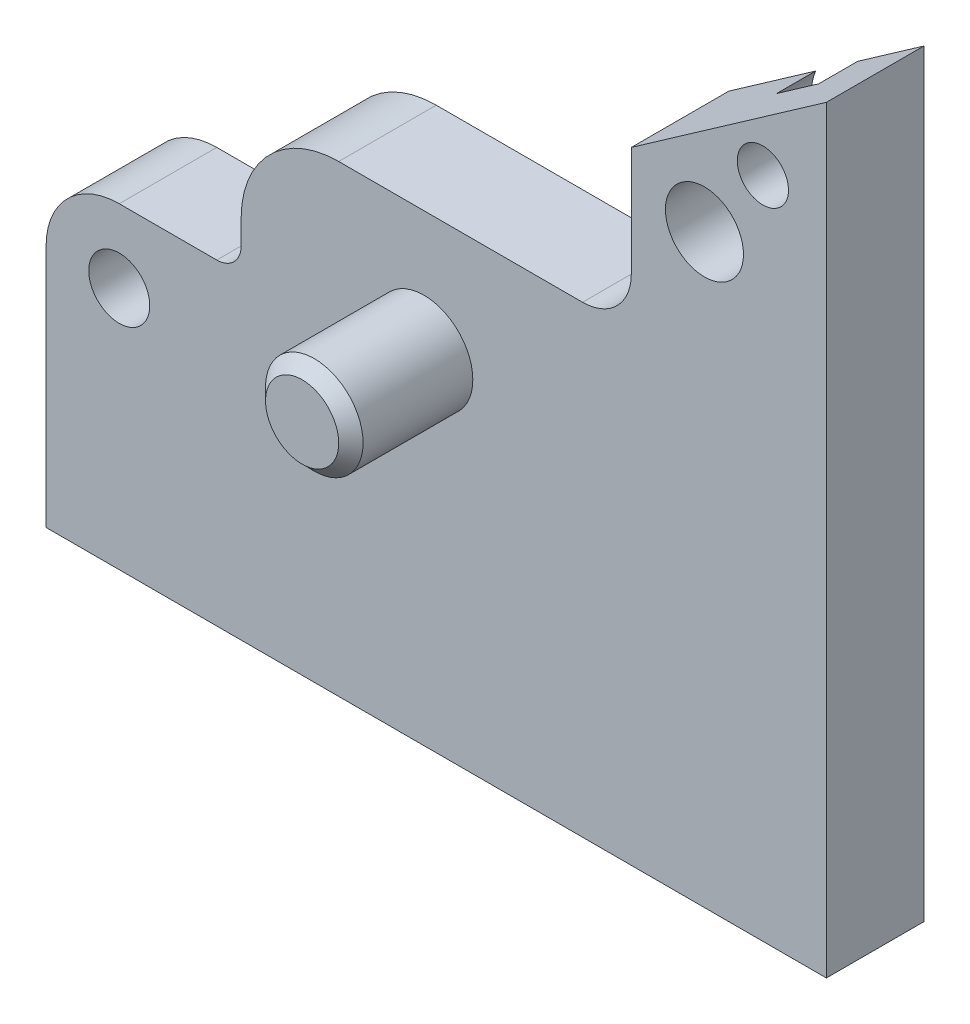
from build123d import *

# Parameters (mm, degrees)
SKETCH1_W                       = 32
SKETCH1_H                       = 25.5
BOSS_EXTRUDE1_DEPTH             = 4
SKETCH2_W                       = 8
SKETCH2_H                       = 12.5
CUT_EXTRUDE1_DEPTH              = 5
SKETCH3_W                       = 16
SKETCH3_H                       = 6.5
CUT_EXTRUDE2_DEPTH              = 5
DRAFT1_ANGLE                    = 35.000000002
SKETCH4_W                       = 2
SKETCH4_H                       = 5
SKETCH5_W                       = 2
SKETCH5_H                       = 5
F_2_5_2_5_DIAMETER_HOLE1_D      = 2.5
F_2_5_2_5_DIAMETER_HOLE1_DEPTH  = 9
F_3_2_3_2_DIAMETER_HOLE1_D      = 3.2
F_3_2_3_2_DIAMETER_HOLE1_DEPTH  = 9
M4X0_7_TAPPED_HOLE1_D           = 2.1
M4X0_7_TAPPED_HOLE1_DEPTH       = 9
M4X0_7_TAPPED_HOLE1_CBORE_D     = 4
M4X0_7_TAPPED_HOLE1_CBORE_DEPTH = 1.6
F_2_5_2_5_DIAMETER_HOLE2_D      = 2.5
F_2_5_2_5_DIAMETER_HOLE2_DEPTH  = 7.5
F_2_5_2_5_DIAMETER_HOLE2_TIP    = 0.751075774
CHAMFER1_SIZE                   = 0.5
FILLET1_R                       = 1
FILLET2_R                       = 2
FILLET3_R                       = 3
FILLET4_R                       = 4


with BuildPart() as part:
    # Sketch1 → Boss-Extrude1 (new body)
    with BuildSketch(Plane.XY.offset(4)):
        with Locations((16, 12.75)):
            Rectangle(SKETCH1_W, SKETCH1_H)
    extrude(amount=-BOSS_EXTRUDE1_DEPTH)

    # Sketch2 → Cut-Extrude1 (cut, through all)
    with BuildSketch(Plane(origin=(0, 0, 0), x_dir=(-1, 0, 0), z_dir=(0, 0, -1))):
        with Locations((-4, 19.25)):
            Rectangle(SKETCH2_W, SKETCH2_H)
    extrude(amount=-CUT_EXTRUDE1_DEPTH, mode=Mode.SUBTRACT)

    # Sketch3 → Cut-Extrude2 (cut, through all)
    with BuildSketch(Plane(origin=(0, 0, 0), x_dir=(-1, 0, 0), z_dir=(0, 0, -1))):
        with Locations((-16, 22.25)):
            Rectangle(SKETCH3_W, SKETCH3_H)
    extrude(amount=-CUT_EXTRUDE2_DEPTH, mode=Mode.SUBTRACT)

    # Draft1
    draft1_faces = [part.faces().sort_by_distance(p)[0] for p in [
        (28, 25.5, 2),
    ]]
    draft(draft1_faces, Plane(origin=(24, 25.5, 4), x_dir=(0, 0, -1), z_dir=(-1, 0, 0)), DRAFT1_ANGLE)

    # Sketch4 → Revolve1 (revolve)
    with BuildSketch(Plane(origin=(0, 5, 0), x_dir=(1, 0, 0), z_dir=(0, 1, 0))):
        with Locations((7, 2.5)):
            Rectangle(SKETCH4_W, SKETCH4_H)
    revolve(axis=Axis((6, 5, -5), (0, 0, 1)))

    # Sketch5 → Revolve2 (revolve)
    with BuildSketch(Plane.XZ.offset(-14)):
        with Locations((16.5, 6.5)):
            Rectangle(SKETCH5_W, SKETCH5_H)
    revolve(axis=Axis((15.5, 14, 9), (0, 0, -1)))

    # Ø2.5 (2.5) Diameter Hole1
    with Locations(Plane.XY.offset(4)):
        with Locations((3, 10)):
            Hole(F_2_5_2_5_DIAMETER_HOLE1_D / 2, depth=F_2_5_2_5_DIAMETER_HOLE1_DEPTH)

    # Ø3.2 (3.2) Diameter Hole1
    with Locations(Plane(origin=(0, 0, 0), x_dir=(-1, 0, 0), z_dir=(0, 0, -1))):
        with Locations((-27, 24)):
            Hole(F_3_2_3_2_DIAMETER_HOLE1_D / 2, depth=F_3_2_3_2_DIAMETER_HOLE1_DEPTH)

    # M4x0.7 Tapped Hole1
    with Locations(Plane(origin=(0, 0, 0), x_dir=(-1, 0, 0), z_dir=(0, 0, -1))):
        with Locations((-29.395995182, 27.202999702)):
            CounterBoreHole(M4X0_7_TAPPED_HOLE1_D / 2, M4X0_7_TAPPED_HOLE1_CBORE_D / 2, M4X0_7_TAPPED_HOLE1_CBORE_DEPTH, depth=M4X0_7_TAPPED_HOLE1_DEPTH)

    # Ø2.5 (2.5) Diameter Hole2
    with Locations(Plane(origin=(0, 0, 0), x_dir=(-1, 0, 0), z_dir=(0, -1, 0))):
        with Locations((-10, -2), (-19.5, -2), (-29, -2)):
            Hole(F_2_5_2_5_DIAMETER_HOLE2_D / 2, depth=F_2_5_2_5_DIAMETER_HOLE2_DEPTH)
            with Locations((0, 0, -(F_2_5_2_5_DIAMETER_HOLE2_DEPTH + F_2_5_2_5_DIAMETER_HOLE2_TIP / 2))):  # 118° drill point
                Cone(0, F_2_5_2_5_DIAMETER_HOLE2_D / 2, F_2_5_2_5_DIAMETER_HOLE2_TIP, mode=Mode.SUBTRACT)

    # Chamfer1
    chamfer1_edges = [part.edges().sort_by_distance(p)[0] for p in [
        (4, 5, -5),
        (13.5, 14, 9),
    ]]
    chamfer(chamfer1_edges, length=CHAMFER1_SIZE)

    # Fillet1
    fillet1_edges = [part.edges().sort_by_distance(p)[0] for p in [
        (8, 13, 2),
    ]]
    fillet(fillet1_edges, radius=FILLET1_R)

    # Fillet2
    fillet2_edges = [part.edges().sort_by_distance(p)[0] for p in [
        (24, 19, 2),
    ]]
    fillet(fillet2_edges, radius=FILLET2_R)

    # Fillet3
    fillet3_edges = [part.edges().sort_by_distance(p)[0] for p in [
        (0, 13, 2),
    ]]
    fillet(fillet3_edges, radius=FILLET3_R)

    # Fillet4
    fillet4_edges = [part.edges().sort_by_distance(p)[0] for p in [
        (8, 19, 2),
    ]]
    fillet(fillet4_edges, radius=FILLET4_R)


solid = part.part
